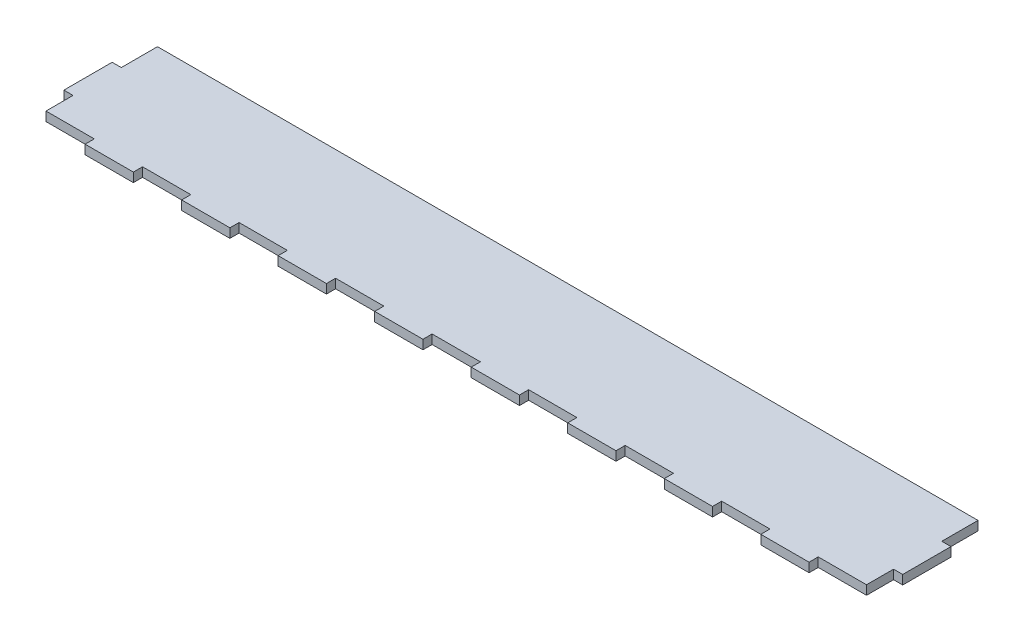
from build123d import *

# Parameters (mm, degrees)
BOSS_EXTRUDE1_DEPTH = 4.826


with BuildPart() as part:
    # Sketch2 → Boss-Extrude1 (new body)
    with BuildSketch(Plane(origin=(0, 0, 0), x_dir=(1, 0, 0), z_dir=(0, 1, 0))):
        Polygon((120.65, 0), (146.05, 0), (146.05, 4.826), (171.45, 4.826), (171.45, 0), (196.85, 0), (196.85, 4.826), (222.25, 4.826), (222.25, 0), (247.65, 0), (247.65, 4.826), (273.05, 4.826), (273.05, 0), (298.45, 0), (298.45, 4.826), (323.85, 4.826), (323.85, 0), (349.25, 0), (349.25, 4.826), (374.65, 4.826), (374.65, 0), (400.05, 0), (400.05, 4.826), (425.45, 4.826), (425.45, 0), (450.85, 0), (450.85, 4.826), (476.25, 4.826), (476.25, 0), (501.65, 0), (501.65, 4.826), (527.05, 4.826), (527.05, 19.05), (531.876, 19.05), (531.876, 44.45), (527.05, 44.45), (527.05, 63.5), (95.25, 63.5), (95.25, 44.45), (90.424, 44.45), (90.424, 19.05), (95.25, 19.05), (95.25, 4.826), (120.65, 4.826), align=None)
    extrude(amount=BOSS_EXTRUDE1_DEPTH)


solid = part.part
